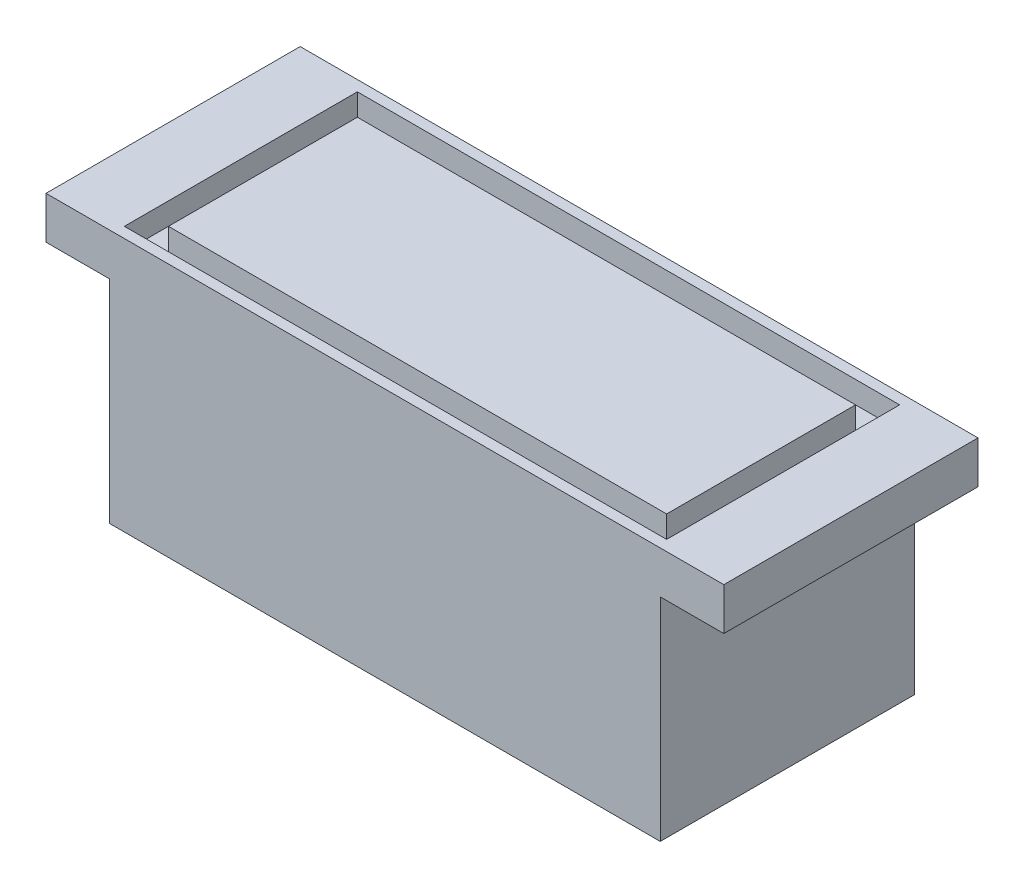
from build123d import *

# Parameters (mm, degrees)
BOSS_EXTRUDE1_DEPTH = 38.1
SKETCH2_W           = 81.28
SKETCH2_H           = 34.925
SKETCH2_W_2         = 74.676
SKETCH2_H_2         = 28.321
CUT_EXTRUDE1_DEPTH  = 3.302


with BuildPart() as part:
    # Sketch1 → Boss-Extrude1 (new body)
    with BuildSketch(Plane.XY):
        Polygon((-50.8, 0), (-50.8, -6.35), (-41.275, -6.35), (-41.275, -38.1), (41.275, -38.1), (41.275, -6.35), (50.8, -6.35), (50.8, 0), align=None)
    extrude(amount=BOSS_EXTRUDE1_DEPTH)

    # Sketch2 → Cut-Extrude1 (cut)
    with BuildSketch(Plane(origin=(0, 0, 0), x_dir=(1, 0, 0), z_dir=(0, 1, 0))):
        with Locations((0, -19.05)):
            Rectangle(SKETCH2_W, SKETCH2_H)
        with Locations((0, -19.05)):
            Rectangle(SKETCH2_W_2, SKETCH2_H_2, mode=Mode.SUBTRACT)
    extrude(amount=-CUT_EXTRUDE1_DEPTH, mode=Mode.SUBTRACT)


solid = part.part
